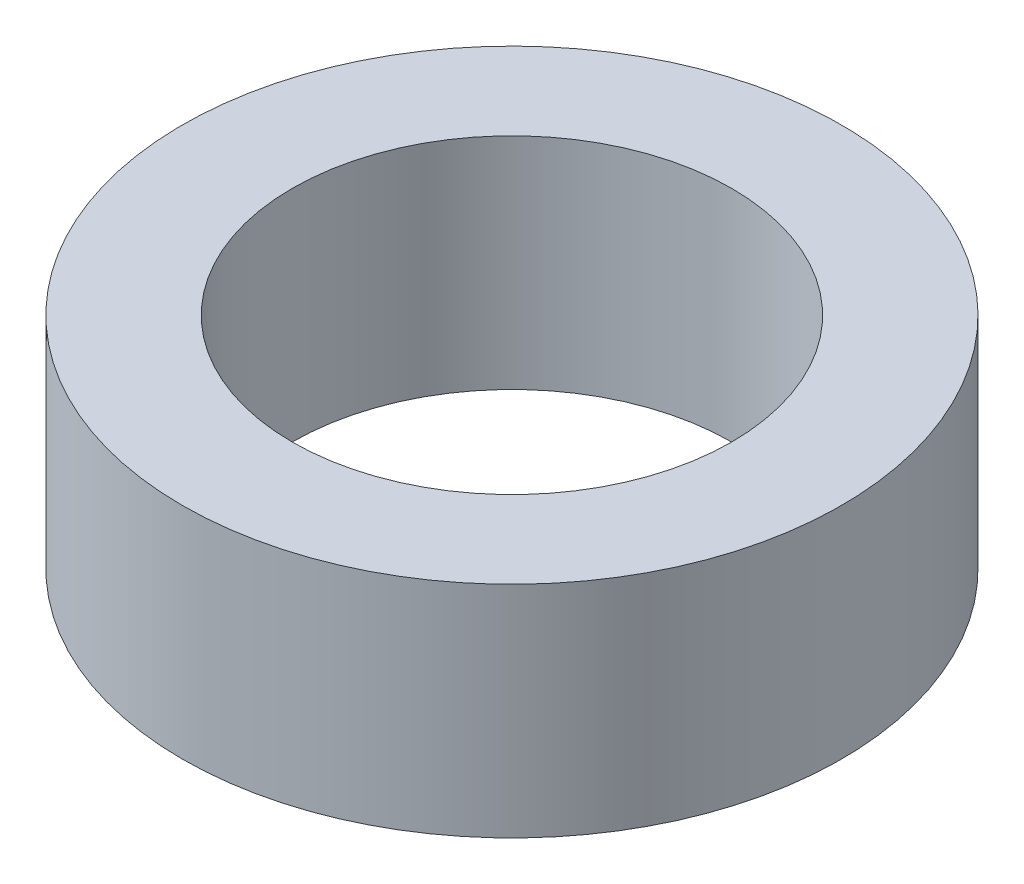
from build123d import *

# Parameters (mm, degrees)
SKETCH1_R           = 4.7625
SKETCH1_R_2         = 3.175
BOSS_EXTRUDE3_DEPTH = 3.175


with BuildPart() as part:
    # Sketch1 → Boss-Extrude3 (new body)
    with BuildSketch(Plane(origin=(0, 0, 0), x_dir=(1, 0, 0), z_dir=(0, 1, 0))):
        Circle(SKETCH1_R)
        Circle(SKETCH1_R_2, mode=Mode.SUBTRACT)
    extrude(amount=BOSS_EXTRUDE3_DEPTH)


solid = part.part
